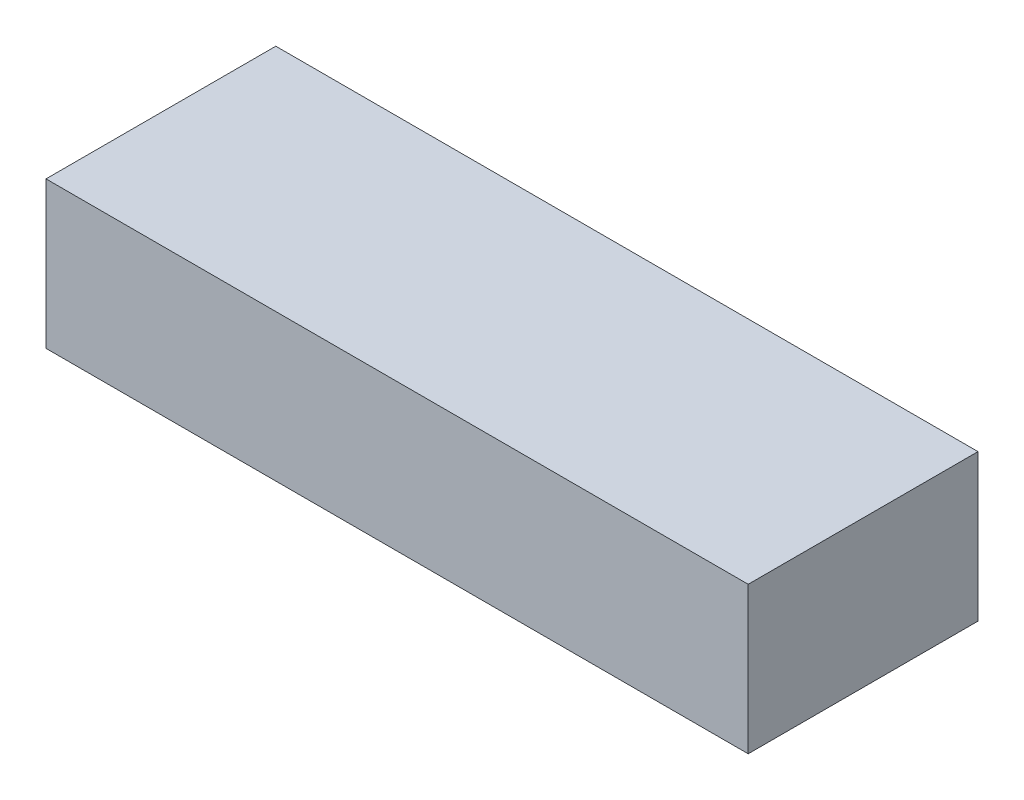
from build123d import *

# Parameters (mm, degrees)
SKETCH1_W           = 110
SKETCH1_H           = 36
BOSS_EXTRUDE1_DEPTH = 23


with BuildPart() as part:
    # Sketch1 → Boss-Extrude1 (new body)
    with BuildSketch(Plane(origin=(0, 0, 0), x_dir=(1, 0, 0), z_dir=(0, 1, 0))):
        Rectangle(SKETCH1_W, SKETCH1_H)
    extrude(amount=BOSS_EXTRUDE1_DEPTH)


solid = part.part
